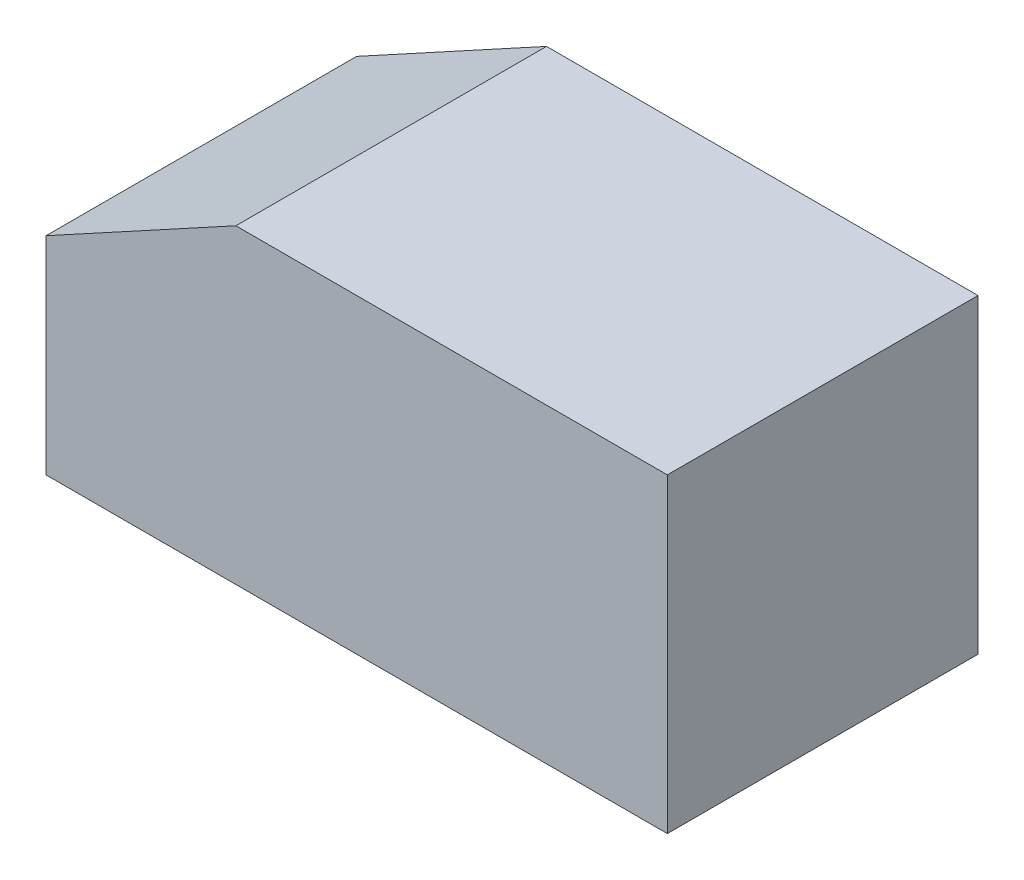
from build123d import *

# Parameters (mm, degrees)
EXTRUDE_1_DEPTH = 18


with BuildPart() as part:
    # 草图1 → 凸台-拉伸1 (new body)
    with BuildSketch(Plane.XY):
        Polygon((-31.543597346, 3.672989534), (-31.543597346, -8.327010466), (-1.543597346, -8.327010466), (4.456402654, -8.327010466), (4.456402654, 9.672989534), (-20.543597346, 9.672989534), align=None)
    extrude(amount=EXTRUDE_1_DEPTH)


solid = part.part
